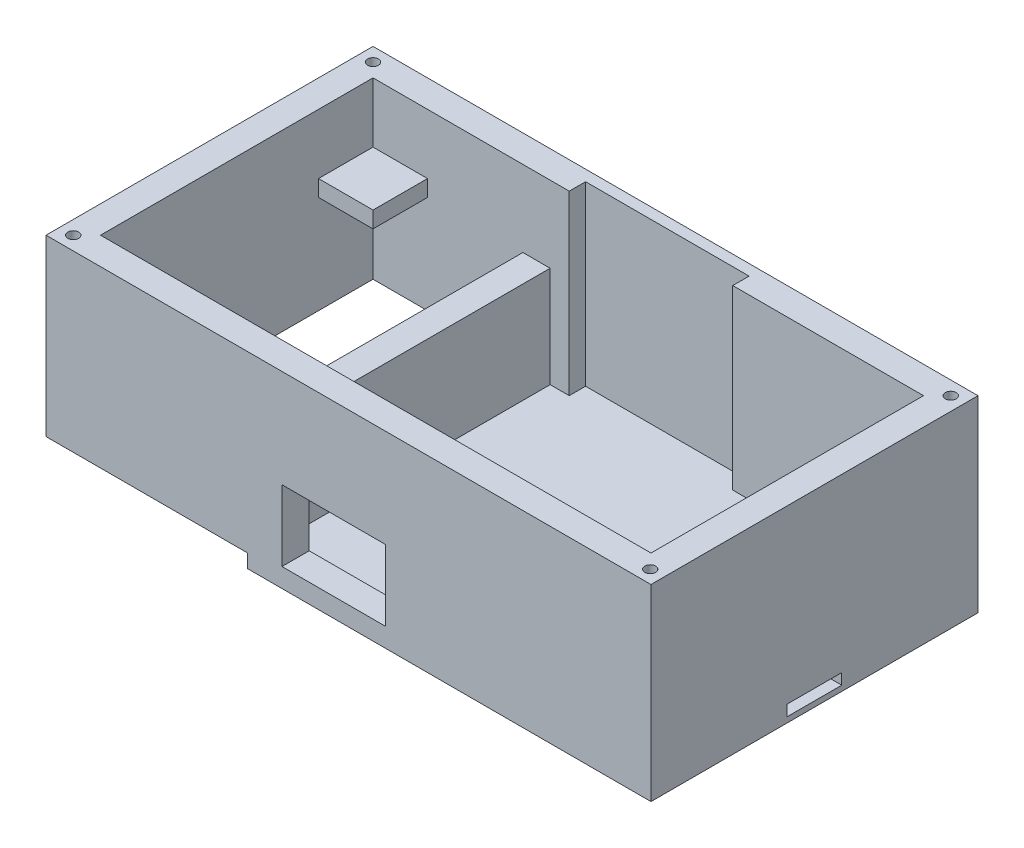
from build123d import *

# Parameters (mm, degrees)
SKETCH1_W           = 111
SKETCH1_H           = 60
BOSS_EXTRUDE1_DEPTH = 34.5
SKETCH2_W           = 101
SKETCH2_H           = 50
CUT_EXTRUDE1_DEPTH  = 11
CUT_EXTRUDE3_DEPTH  = 14
CUT_EXTRUDE5_START  = -2
SKETCH5_W           = 27.5
SKETCH5_H           = 50
SKETCH5_W_2         = 68.5
CUT_EXTRUDE5_DEPTH  = 18.5
SKETCH6_W           = 37
SKETCH6_H           = 60
CUT_EXTRUDE6_DEPTH  = 2.5
SKETCH7_R           = 1
CUT_EXTRUDE7_DEPTH  = 4
SKETCH8_R           = 1
CUT_EXTRUDE8_DEPTH  = 4
SKETCH9_W           = 19
SKETCH9_H           = 13
CUT_EXTRUDE9_DEPTH  = 10
SKETCH10_W          = 10
SKETCH10_H          = 2
CUT_EXTRUDE10_DEPTH = 70
SKETCH11_W          = 2
SKETCH11_H          = 10
CUT_EXTRUDE11_DEPTH = 2
SKETCH12_W          = 30
SKETCH12_H          = 3
CUT_EXTRUDE12_DEPTH = 32.5


with BuildPart() as part:
    # Sketch1 → Boss-Extrude1 (new body)
    with BuildSketch(Plane(origin=(0, 0, 0), x_dir=(1, 0, 0), z_dir=(0, 1, 0))):
        with Locations((55.5, 30)):
            Rectangle(SKETCH1_W, SKETCH1_H)
    extrude(amount=BOSS_EXTRUDE1_DEPTH)

    # Sketch2 → Cut-Extrude1 (cut)
    with BuildSketch(Plane(origin=(0, 34.5, 0), x_dir=(1, 0, 0), z_dir=(0, 1, 0))):
        with Locations((55.5, 30)):
            Rectangle(SKETCH2_W, SKETCH2_H)
    extrude(amount=-CUT_EXTRUDE1_DEPTH, mode=Mode.SUBTRACT)

    # Sketch3 → Cut-Extrude3 (cut)
    with BuildSketch(Plane(origin=(0, 34.5, 0), x_dir=(1, 0, 0), z_dir=(0, 1, 0))):
        Polygon((5, 45), (15, 45), (15, 55), (96, 55), (96, 45), (106, 45), (106, 15), (96, 15), (96, 5), (15, 5), (15, 15), (5, 15), align=None)
    extrude(amount=-CUT_EXTRUDE3_DEPTH, mode=Mode.SUBTRACT)

    # Sketch5 → Cut-Extrude5 (cut)
    with BuildSketch(Plane.XZ.offset(CUT_EXTRUDE5_START)):
        with Locations((18.75, -30)):
            Rectangle(SKETCH5_W, SKETCH5_H)
        with Locations((71.75, -30)):
            Rectangle(SKETCH5_W_2, SKETCH5_H)
    extrude(amount=-CUT_EXTRUDE5_DEPTH, mode=Mode.SUBTRACT)

    # Sketch6 → Cut-Extrude6 (cut)
    with BuildSketch(Plane.XZ):
        with Locations((18.5, -30)):
            Rectangle(SKETCH6_W, SKETCH6_H)
    extrude(amount=-CUT_EXTRUDE6_DEPTH, mode=Mode.SUBTRACT)

    # Sketch7 → Cut-Extrude7 (cut)
    with BuildSketch(Plane(origin=(0, 2.5, 0), x_dir=(-1, 0, 0), z_dir=(0, -1, 0))):
        with Locations((-2.5, 57.5)):
            Circle(SKETCH7_R)
        with Locations((-34.5, 57.5)):
            Circle(SKETCH7_R)
        with Locations((-34.5, 2.5)):
            Circle(SKETCH7_R)
        with Locations((-2.5, 2.5)):
            Circle(SKETCH7_R)
    extrude(amount=-CUT_EXTRUDE7_DEPTH, mode=Mode.SUBTRACT)

    # Sketch8 → Cut-Extrude8 (cut)
    with BuildSketch(Plane(origin=(0, 34.5, 0), x_dir=(1, 0, 0), z_dir=(0, 1, 0))):
        with Locations((2.5, 57.5)):
            Circle(SKETCH8_R)
        with Locations((108.5, 57.5)):
            Circle(SKETCH8_R)
        with Locations((108.5, 2.360383006)):
            Circle(SKETCH8_R)
        with Locations((2.5, 2.5)):
            Circle(SKETCH8_R)
    extrude(amount=-CUT_EXTRUDE8_DEPTH, mode=Mode.SUBTRACT)

    # Sketch9 → Cut-Extrude9 (cut)
    with BuildSketch(Plane.XY):
        with Locations((52.792502494, 10)):
            Rectangle(SKETCH9_W, SKETCH9_H)
    extrude(amount=-CUT_EXTRUDE9_DEPTH, mode=Mode.SUBTRACT)

    # Sketch10 → Cut-Extrude10 (cut)
    with BuildSketch(Plane(origin=(111, 0, 0), x_dir=(0, 0, -1), z_dir=(1, 0, 0))):
        with Locations((30, 2)):
            Rectangle(SKETCH10_W, SKETCH10_H)
    extrude(amount=-CUT_EXTRUDE10_DEPTH, mode=Mode.SUBTRACT)

    # Sketch11 → Cut-Extrude11 (cut, through all)
    with BuildSketch(Plane(origin=(0, 1, 0), x_dir=(1, 0, 0), z_dir=(0, 1, 0))):
        with Locations((42, 30)):
            Rectangle(SKETCH11_W, SKETCH11_H)
    extrude(amount=-CUT_EXTRUDE11_DEPTH, mode=Mode.SUBTRACT)

    # Sketch12 → Cut-Extrude12 (cut)
    with BuildSketch(Plane(origin=(0, 34.5, 0), x_dir=(1, 0, 0), z_dir=(0, 1, 0))):
        with Locations((56, 56.5)):
            Rectangle(SKETCH12_W, SKETCH12_H)
    extrude(amount=-CUT_EXTRUDE12_DEPTH, mode=Mode.SUBTRACT)


solid = part.part
